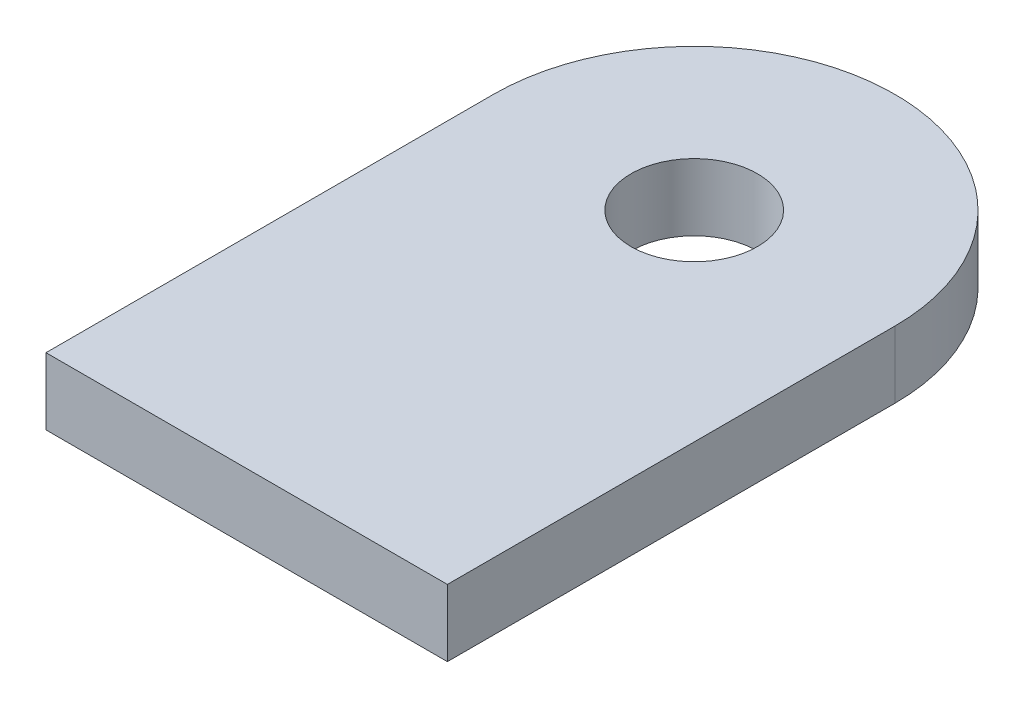
from build123d import *

# Parameters (mm, degrees)
SKETCH1_R           = 3
BOSS_EXTRUDE1_DEPTH = 3.175


with BuildPart() as part:
    # Sketch1 → Boss-Extrude1 (new body)
    with BuildSketch(Plane(origin=(0, 0, 0), x_dir=(1, 0, 0), z_dir=(0, 1, 0))):
        with BuildLine():
            Line((-9.525, 0), (-9.525, -21.24))
            Line((-9.525, -21.24), (9.525, -21.24))
            Line((9.525, -21.24), (9.525, 0))
            ThreePointArc((9.525, 0), (0, 9.525), (-9.525, 0))
        make_face()
        Circle(SKETCH1_R, mode=Mode.SUBTRACT)
    extrude(amount=BOSS_EXTRUDE1_DEPTH)


solid = part.part
